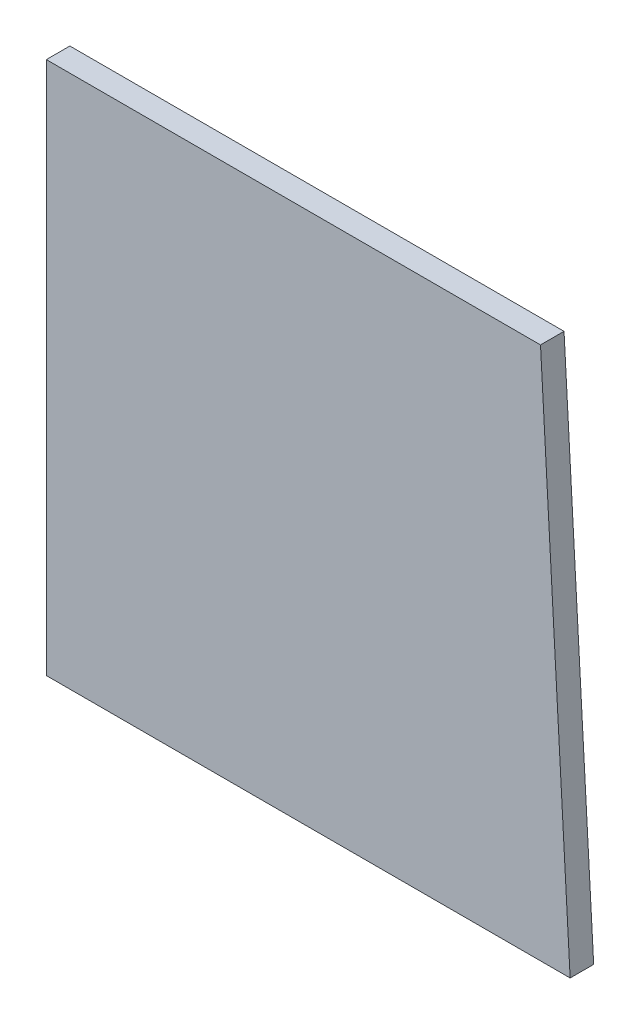
from build123d import *

# Parameters (mm, degrees)
BOSS_EXTRUDE1_DEPTH = 3


with BuildPart() as part:
    # Sketch1 → Boss-Extrude1 (new body)
    with BuildSketch(Plane.XY):
        Polygon((-33.590794433, -33.180041654), (33.18081526, -33.180041654), (29.403037483, 34.819958346), (-33.590794433, 34.819958346), align=None)
    extrude(amount=BOSS_EXTRUDE1_DEPTH)


solid = part.part
